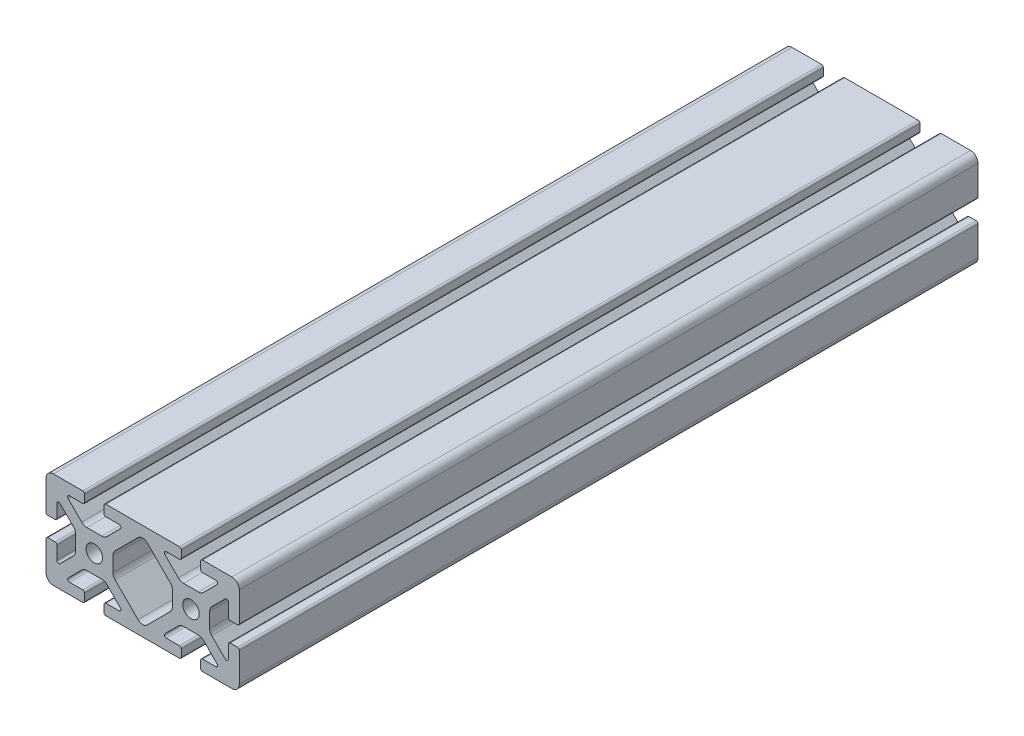
from build123d import *

# Parameters (mm, degrees)
SKETCH1_R           = 3.4036
BOSS_EXTRUDE1_DEPTH = 152.4


with BuildPart() as part:
    # Sketch1 → Boss-Extrude1 (new body, symmetric)
    with BuildSketch(Plane.XY):
        with BuildLine():
            Line((-39.878, 16.891), (-39.878, 4.7625))
            ThreePointArc((-39.878, 4.7625), (-39.654815367, 4.223684633), (-39.116, 4.0005))
            Line((-39.116, 4.0005), (-36.1442, 4.0005))
            ThreePointArc((-36.1442, 4.0005), (-35.605384633, 4.223684633), (-35.3822, 4.7625))
            Line((-35.3822, 4.7625), (-35.3822, 10.2235))
            ThreePointArc((-35.3822, 10.2235), (-34.911804775, 10.927496204), (-34.081384633, 10.762315367))
            Line((-34.081384633, 10.762315367), (-28.513059555, 5.19399029))
            ThreePointArc((-28.513059555, 5.19399029), (-27.863348265, 4.221628629), (-27.6352, 3.074649845))
            Line((-27.6352, 3.074649845), (-27.6352, -3.074649845))
            ThreePointArc((-27.6352, -3.074649845), (-27.863348265, -4.221628629), (-28.513059555, -5.19399029))
            Line((-28.513059555, -5.19399029), (-34.081384633, -10.762315367))
            ThreePointArc((-34.081384633, -10.762315367), (-34.911804775, -10.927496204), (-35.3822, -10.2235))
            Line((-35.3822, -10.2235), (-35.3822, -4.7625))
            ThreePointArc((-35.3822, -4.7625), (-35.605384633, -4.223684633), (-36.1442, -4.0005))
            Line((-36.1442, -4.0005), (-39.116, -4.0005))
            ThreePointArc((-39.116, -4.0005), (-39.654815367, -4.223684633), (-39.878, -4.7625))
            Line((-39.878, -4.7625), (-39.878, -16.891))
            ThreePointArc((-39.878, -16.891), (-38.985261469, -19.046261469), (-36.83, -19.939))
            Line((-36.83, -19.939), (-24.7015, -19.939))
            ThreePointArc((-24.7015, -19.939), (-24.162684633, -19.715815367), (-23.9395, -19.177))
            Line((-23.9395, -19.177), (-23.9395, -16.2052))
            ThreePointArc((-23.9395, -16.2052), (-24.162684633, -15.666384633), (-24.7015, -15.4432))
            Line((-24.7015, -15.4432), (-30.1625, -15.4432))
            ThreePointArc((-30.1625, -15.4432), (-30.866496204, -14.972804775), (-30.701315367, -14.142384633))
            Line((-30.701315367, -14.142384633), (-25.13299029, -8.574059555))
            ThreePointArc((-25.13299029, -8.574059555), (-24.160628629, -7.924348265), (-23.013649845, -7.6962))
            Line((-23.013649845, -7.6962), (-16.864350155, -7.6962))
            ThreePointArc((-16.864350155, -7.6962), (-15.717371371, -7.924348265), (-14.74500971, -8.574059555))
            Line((-14.74500971, -8.574059555), (-9.176684633, -14.142384633))
            ThreePointArc((-9.176684633, -14.142384633), (-9.011503796, -14.972804775), (-9.7155, -15.4432))
            Line((-9.7155, -15.4432), (-15.1765, -15.4432))
            ThreePointArc((-15.1765, -15.4432), (-15.715315367, -15.666384633), (-15.9385, -16.2052))
            Line((-15.9385, -16.2052), (-15.9385, -19.177))
            ThreePointArc((-15.9385, -19.177), (-15.715315367, -19.715815367), (-15.1765, -19.939))
            Line((-15.1765, -19.939), (15.1765, -19.939))
            ThreePointArc((15.1765, -19.939), (15.715315367, -19.715815367), (15.9385, -19.177))
            Line((15.9385, -19.177), (15.9385, -16.2052))
            ThreePointArc((15.9385, -16.2052), (15.715315367, -15.666384633), (15.1765, -15.4432))
            Line((15.1765, -15.4432), (9.7155, -15.4432))
            ThreePointArc((9.7155, -15.4432), (9.011503796, -14.972804775), (9.176684633, -14.142384633))
            Line((9.176684633, -14.142384633), (14.74500971, -8.574059555))
            ThreePointArc((14.74500971, -8.574059555), (15.717371371, -7.924348265), (16.864350155, -7.6962))
            Line((16.864350155, -7.6962), (23.013649845, -7.6962))
            ThreePointArc((23.013649845, -7.6962), (24.160628629, -7.924348265), (25.13299029, -8.574059555))
            Line((25.13299029, -8.574059555), (30.701315367, -14.142384633))
            ThreePointArc((30.701315367, -14.142384633), (30.866496204, -14.972804775), (30.1625, -15.4432))
            Line((30.1625, -15.4432), (24.7015, -15.4432))
            ThreePointArc((24.7015, -15.4432), (24.162684633, -15.666384633), (23.9395, -16.2052))
            Line((23.9395, -16.2052), (23.9395, -19.177))
            ThreePointArc((23.9395, -19.177), (24.162684633, -19.715815367), (24.7015, -19.939))
            Line((24.7015, -19.939), (36.83, -19.939))
            ThreePointArc((36.83, -19.939), (38.985261469, -19.046261469), (39.878, -16.891))
            Line((39.878, -16.891), (39.878, -4.7625))
            ThreePointArc((39.878, -4.7625), (39.654815367, -4.223684633), (39.116, -4.0005))
            Line((39.116, -4.0005), (36.1442, -4.0005))
            ThreePointArc((36.1442, -4.0005), (35.605384633, -4.223684633), (35.3822, -4.7625))
            Line((35.3822, -4.7625), (35.3822, -10.2235))
            ThreePointArc((35.3822, -10.2235), (34.911804775, -10.927496204), (34.081384633, -10.762315367))
            Line((34.081384633, -10.762315367), (28.513059555, -5.19399029))
            ThreePointArc((28.513059555, -5.19399029), (27.863348265, -4.221628629), (27.6352, -3.074649845))
            Line((27.6352, -3.074649845), (27.6352, 3.074649845))
            ThreePointArc((27.6352, 3.074649845), (27.863348265, 4.221628629), (28.513059555, 5.19399029))
            Line((28.513059555, 5.19399029), (34.081384633, 10.762315367))
            ThreePointArc((34.081384633, 10.762315367), (34.911804775, 10.927496204), (35.3822, 10.2235))
            Line((35.3822, 10.2235), (35.3822, 4.7625))
            ThreePointArc((35.3822, 4.7625), (35.605384633, 4.223684633), (36.1442, 4.0005))
            Line((36.1442, 4.0005), (39.116, 4.0005))
            ThreePointArc((39.116, 4.0005), (39.654815367, 4.223684633), (39.878, 4.7625))
            Line((39.878, 4.7625), (39.878, 16.891))
            ThreePointArc((39.878, 16.891), (38.985261469, 19.046261469), (36.83, 19.939))
            Line((36.83, 19.939), (24.7015, 19.939))
            ThreePointArc((24.7015, 19.939), (24.162684633, 19.715815367), (23.9395, 19.177))
            Line((23.9395, 19.177), (23.9395, 16.2052))
            ThreePointArc((23.9395, 16.2052), (24.162684633, 15.666384633), (24.7015, 15.4432))
            Line((24.7015, 15.4432), (30.1625, 15.4432))
            ThreePointArc((30.1625, 15.4432), (30.866496204, 14.972804775), (30.701315367, 14.142384633))
            Line((30.701315367, 14.142384633), (25.13299029, 8.574059555))
            ThreePointArc((25.13299029, 8.574059555), (24.160628629, 7.924348265), (23.013649845, 7.6962))
            Line((23.013649845, 7.6962), (16.864350155, 7.6962))
            ThreePointArc((16.864350155, 7.6962), (15.717371371, 7.924348265), (14.74500971, 8.574059555))
            Line((14.74500971, 8.574059555), (9.176684633, 14.142384633))
            ThreePointArc((9.176684633, 14.142384633), (9.011503796, 14.972804775), (9.7155, 15.4432))
            Line((9.7155, 15.4432), (15.1765, 15.4432))
            ThreePointArc((15.1765, 15.4432), (15.715315367, 15.666384633), (15.9385, 16.2052))
            Line((15.9385, 16.2052), (15.9385, 19.177))
            ThreePointArc((15.9385, 19.177), (15.715315367, 19.715815367), (15.1765, 19.939))
            Line((15.1765, 19.939), (-15.1765, 19.939))
            ThreePointArc((-15.1765, 19.939), (-15.715315367, 19.715815367), (-15.9385, 19.177))
            Line((-15.9385, 19.177), (-15.9385, 16.2052))
            ThreePointArc((-15.9385, 16.2052), (-15.715315367, 15.666384633), (-15.1765, 15.4432))
            Line((-15.1765, 15.4432), (-9.7155, 15.4432))
            ThreePointArc((-9.7155, 15.4432), (-9.011503796, 14.972804775), (-9.176684633, 14.142384633))
            Line((-9.176684633, 14.142384633), (-14.74500971, 8.574059555))
            ThreePointArc((-14.74500971, 8.574059555), (-15.717371371, 7.924348265), (-16.864350155, 7.6962))
            Line((-16.864350155, 7.6962), (-23.013649845, 7.6962))
            ThreePointArc((-23.013649845, 7.6962), (-24.160628629, 7.924348265), (-25.13299029, 8.574059555))
            Line((-25.13299029, 8.574059555), (-30.701315367, 14.142384633))
            ThreePointArc((-30.701315367, 14.142384633), (-30.866496204, 14.972804775), (-30.1625, 15.4432))
            Line((-30.1625, 15.4432), (-24.7015, 15.4432))
            ThreePointArc((-24.7015, 15.4432), (-24.162684633, 15.666384633), (-23.9395, 16.2052))
            Line((-23.9395, 16.2052), (-23.9395, 19.177))
            ThreePointArc((-23.9395, 19.177), (-24.162684633, 19.715815367), (-24.7015, 19.939))
            Line((-24.7015, 19.939), (-36.83, 19.939))
            ThreePointArc((-36.83, 19.939), (-38.985261469, 19.046261469), (-39.878, 16.891))
        make_face()
        with Locations((-19.939, 0)):
            Circle(SKETCH1_R, mode=Mode.SUBTRACT)
        with Locations((19.939, 0)):
            Circle(SKETCH1_R, mode=Mode.SUBTRACT)
        with BuildLine():
            Line((-12.2428, 3.074649845), (-12.2428, -3.074649845))
            ThreePointArc((-12.2428, -3.074649845), (-12.014651735, -4.221628629), (-11.364940445, -5.19399029))
            Line((-11.364940445, -5.19399029), (-1.904671503, -14.654259232))
            ThreePointArc((-1.904671503, -14.654259232), (0, -15.4432), (1.904671503, -14.654259232))
            Line((1.904671503, -14.654259232), (11.364940445, -5.19399029))
            ThreePointArc((11.364940445, -5.19399029), (12.014651735, -4.221628629), (12.2428, -3.074649845))
            Line((12.2428, -3.074649845), (12.2428, 3.074649845))
            ThreePointArc((12.2428, 3.074649845), (12.014651735, 4.221628629), (11.364940445, 5.19399029))
            Line((11.364940445, 5.19399029), (1.904671503, 14.654259232))
            ThreePointArc((1.904671503, 14.654259232), (0, 15.4432), (-1.904671503, 14.654259232))
            Line((-1.904671503, 14.654259232), (-11.364940445, 5.19399029))
            ThreePointArc((-11.364940445, 5.19399029), (-12.014651735, 4.221628629), (-12.2428, 3.074649845))
        make_face(mode=Mode.SUBTRACT)
    extrude(amount=BOSS_EXTRUDE1_DEPTH, both=True)


solid = part.part
